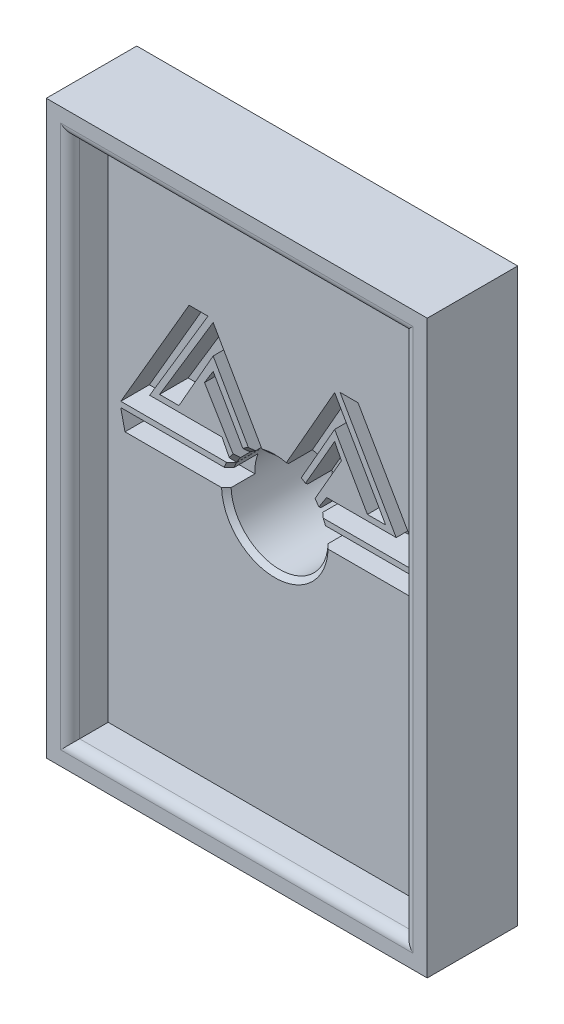
from build123d import *

# Parameters (mm, degrees)
SKETCH1_W           = 20
SKETCH1_H           = 30
BOSS_EXTRUDE1_DEPTH = 5
SKETCH4_W           = 11.5
SKETCH4_H           = 19.5
BOSS_EXTRUDE2_DEPTH = 2.5
SKETCH2_R           = 2.55
CUT_EXTRUDE1_DEPTH  = 8.5
SKETCH3_W           = 17.5
SKETCH3_H           = 27.5
CUT_EXTRUDE2_DEPTH  = 2
FILLET1_R           = 0.5
CHAMFER1_SIZE       = 0.25
CHAMFER2_SIZE       = 0.25
FILLET2_R           = 0.5
CUT_EXTRUDE5_DEPTH  = 3.5


with BuildPart() as part:
    # Sketch1 → Boss-Extrude1 (new body)
    with BuildSketch(Plane.XY):
        Rectangle(SKETCH1_W, SKETCH1_H)
    extrude(amount=BOSS_EXTRUDE1_DEPTH)

    # Sketch4 → Boss-Extrude2 (add)
    with BuildSketch(Plane(origin=(0, 0, 0), x_dir=(-1, 0, 0), z_dir=(0, 0, -1))):
        Rectangle(SKETCH4_W, SKETCH4_H)
    extrude(amount=BOSS_EXTRUDE2_DEPTH)

    # Sketch2 → Cut-Extrude1 (cut, through all)
    with BuildSketch(Plane.XY.offset(5)):
        Circle(SKETCH2_R)
    extrude(amount=-CUT_EXTRUDE1_DEPTH, mode=Mode.SUBTRACT)

    # Sketch3 → Cut-Extrude2 (cut)
    with BuildSketch(Plane.XY.offset(5)):
        Rectangle(SKETCH3_W, SKETCH3_H)
    extrude(amount=-CUT_EXTRUDE2_DEPTH, mode=Mode.SUBTRACT)

    # Fillet1
    fillet1_edges = [part.edges().sort_by_distance(p)[0] for p in [
        (-5.75, 0, -2.5),
        (0, 9.75, -2.5),
        (5.75, 0, -2.5),
        (0, -9.75, -2.5),
        (-2.55, 0, -2.5),
    ]]
    fillet(fillet1_edges, radius=FILLET1_R)

    # Chamfer1
    chamfer1_edges = [part.edges().sort_by_distance(p)[0] for p in [
        (-5.75, 0, 0),
        (0, 9.75, 0),
        (5.75, 0, 0),
        (0, -9.75, 0),
        (0, -15, 0),
        (-10, 0, 0),
        (0, 15, 0),
        (10, 0, 0),
    ]]
    chamfer(chamfer1_edges, length=CHAMFER1_SIZE)

    # Chamfer2
    chamfer2_edges = [part.edges().sort_by_distance(p)[0] for p in [
        (-2.55, 0, 3),
    ]]
    chamfer(chamfer2_edges, length=CHAMFER2_SIZE)

    # Fillet2
    fillet2_edges = [part.edges().sort_by_distance(p)[0] for p in [
        (8.75, 0, 5),
        (0, 13.75, 5),
        (-8.75, 0, 5),
        (0, -13.75, 5),
    ]]
    fillet(fillet2_edges, radius=FILLET2_R)

    # Mobious Logo → Cut-Extrude5 (cut)
    with BuildSketch(Plane(origin=(0, 0, 5), x_dir=(-1, 0, 0), z_dir=(0, 0, 1))):
        Polygon((3.509190245, -7.338202372), (4.502229849, -7.338202372), (8.08727113, -1.177990592), (2.246851765, -1.177990592), (2.773304458, -2.208730349), (6.572464955, -2.208730349), align=None)
        Polygon((3.694333222, -4.224434122), (3.239891369, -4.96500603), (0.344928456, 0.101179067), (7.868465794, 0.101179067), (8.091043636, -0.891860536), (1.68474111, -0.891860536), align=None)
        Polygon((6.050698383, -2.50765379), (3.239891369, -7.186721754), (0.041967221, -1.598400594), (-3.139125747, -7.186721754), (-5.816728556, -2.50765379), (-4.85985244, -2.50765379), (-3.139125747, -5.514596088), (0, 0), (3.239891369, -5.661658206), (5.035275167, -2.50765379), align=None)
        Polygon((-3.425255803, -7.338202372), (-4.367801867, -7.338202372), (-7.91918079, -1.177990592), (-2.061930245, -1.177990592), (-2.718346254, -2.208730349), (-6.370712255, -2.208730349), align=None)
        Polygon((-3.139125747, -4.96500603), (-0.227331655, 0.101179067), (-7.649881914, 0.101179067), (-8.043673481, -0.891860536), (-1.556994853, -0.891860536), (-3.494124276, -4.262241786), align=None)
    extrude(amount=-CUT_EXTRUDE5_DEPTH, mode=Mode.SUBTRACT)


solid = part.part
